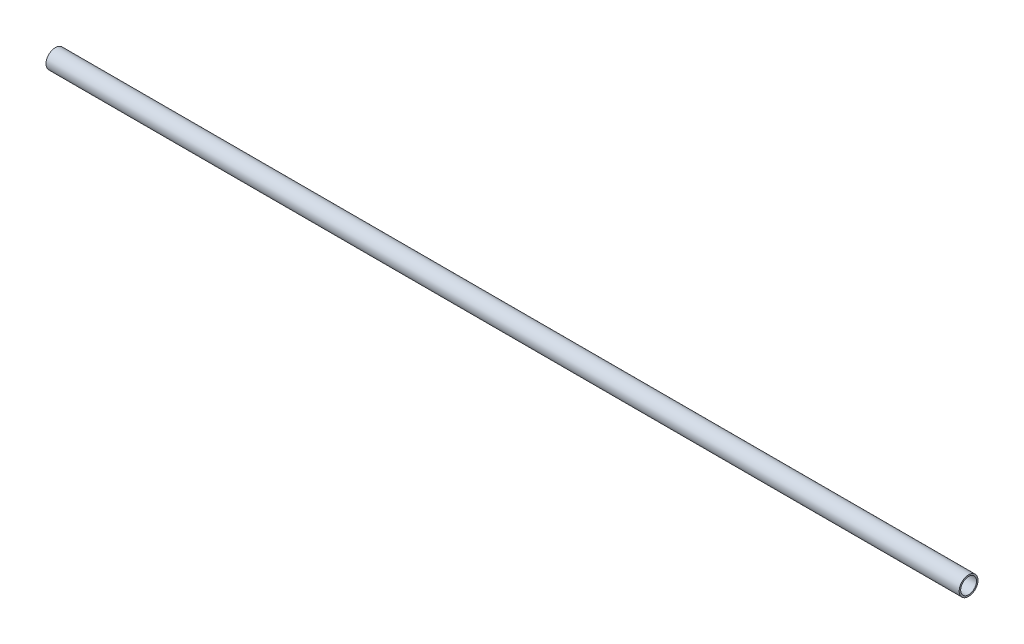
from build123d import *

# Parameters (mm, degrees)
SKETCH1_R           = 3.175
SKETCH1_R_2         = 2.667
BOSS_EXTRUDE1_DEPTH = 307.975


with BuildPart() as part:
    # Sketch1 → Boss-Extrude1 (new body)
    with BuildSketch(Plane(origin=(0, 0, 0), x_dir=(0, 0, -1), z_dir=(1, 0, 0))):
        Circle(SKETCH1_R)
        Circle(SKETCH1_R_2, mode=Mode.SUBTRACT)
    extrude(amount=-BOSS_EXTRUDE1_DEPTH)


solid = part.part
